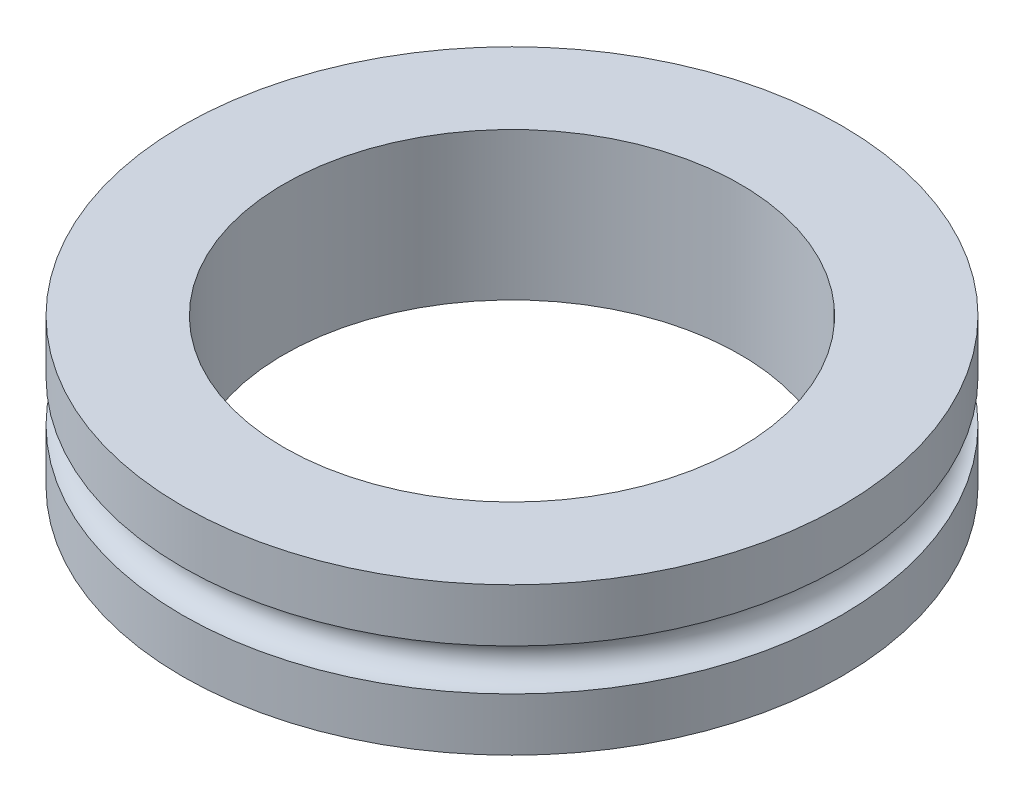
from build123d import *

# Parameters (mm, degrees)
SKETCH1_R           = 15.875
BOSS_EXTRUDE1_DEPTH = 7.112
SKETCH3_R           = 10.99185
CUT_EXTRUDE1_DEPTH  = 10.16


with BuildPart() as part:
    # Sketch1 → Boss-Extrude1 (new body)
    with BuildSketch(Plane(origin=(0, 0, 0), x_dir=(1, 0, 0), z_dir=(0, 1, 0))):
        Circle(SKETCH1_R)
    extrude(amount=BOSS_EXTRUDE1_DEPTH)

    # Sketch2 → Cut-Revolve1 (revolve, cut)
    with BuildSketch(Plane.XY):
        with BuildLine():
            Line((-15.875, 4.556), (-15.875, 2.556))
            ThreePointArc((-15.875, 2.556), (-14.875, 3.556), (-15.875, 4.556))
        make_face()
    revolve(axis=Axis((0, 7.112, 0), (0, -1, 0)), mode=Mode.SUBTRACT)

    # Sketch3 → Cut-Extrude1 (cut)
    with BuildSketch(Plane(origin=(0, 7.112, 0), x_dir=(1, 0, 0), z_dir=(0, 1, 0))):
        Circle(SKETCH3_R)
    extrude(amount=-CUT_EXTRUDE1_DEPTH, mode=Mode.SUBTRACT)


solid = part.part
